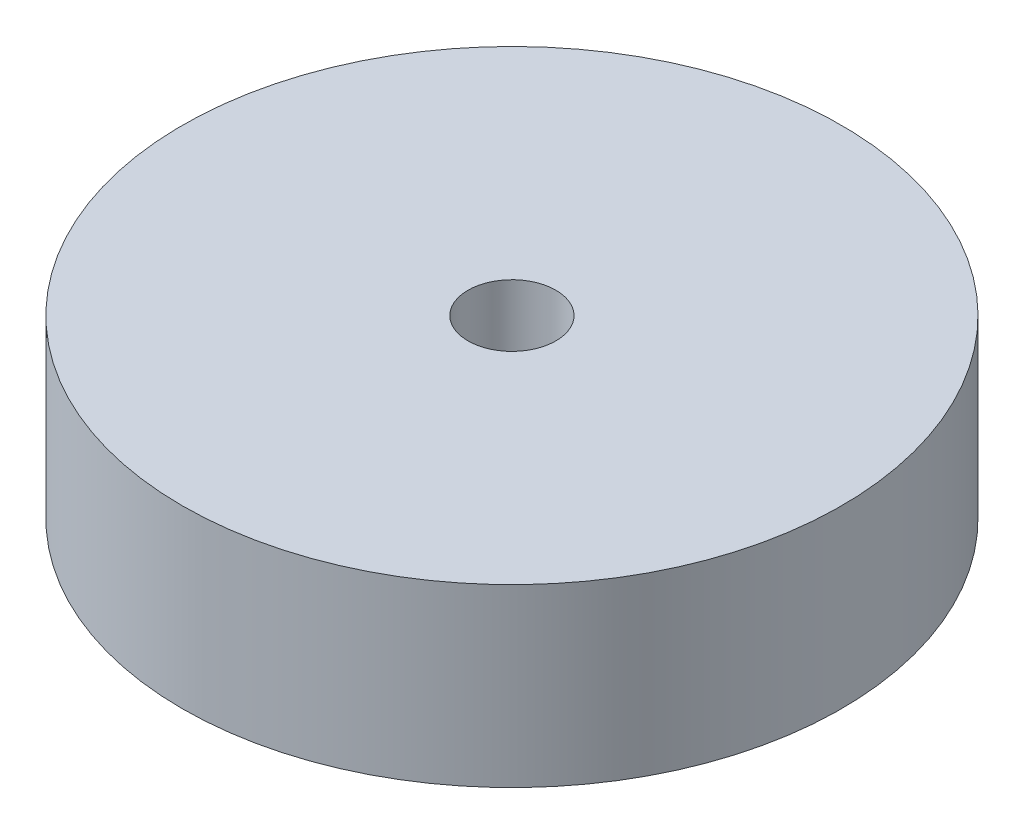
from build123d import *

# Parameters (mm, degrees)
SKETCH1_R           = 47.625
BOSS_EXTRUDE1_DEPTH = 25.4
SKETCH2_R           = 6.35
CUT_EXTRUDE1_DEPTH  = 25.4


with BuildPart() as part:
    # Sketch1 → Boss-Extrude1 (new body)
    with BuildSketch(Plane(origin=(0, 0, 0), x_dir=(1, 0, 0), z_dir=(0, 1, 0))):
        Circle(SKETCH1_R)
    extrude(amount=BOSS_EXTRUDE1_DEPTH)

    # Sketch2 → Cut-Extrude1 (cut)
    with BuildSketch(Plane.XZ):
        Circle(SKETCH2_R)
    extrude(amount=-CUT_EXTRUDE1_DEPTH, mode=Mode.SUBTRACT)


solid = part.part
